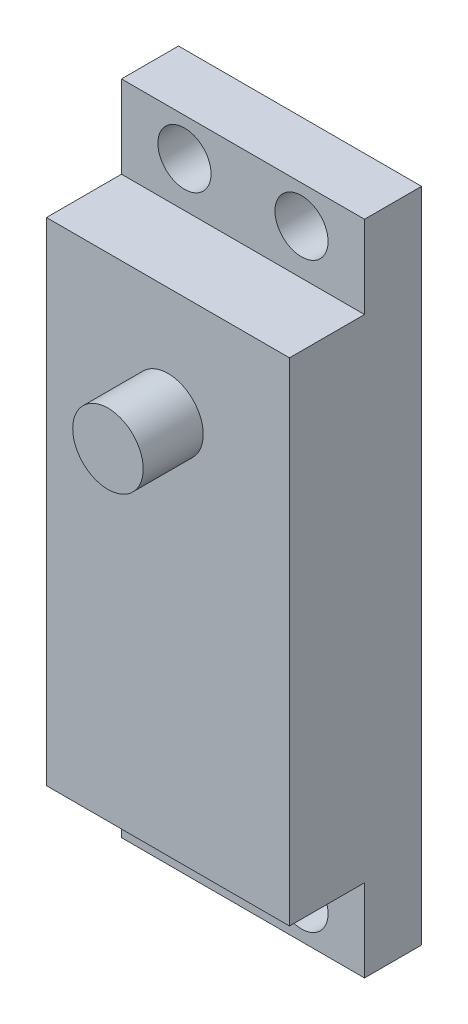
from build123d import *

# Parameters (mm, degrees)
SKETCH1_W             = 20.574
SKETCH1_H             = 55.626
BOSS_EXTRUDE1_DEPTH   = 11.176
SKETCH2_R             = 2.9845
BOSS_EXTRUDE2_DEPTH   = 5.08
F_8_CLEARANCE_HOLE1_D = 4.4958
MIRROR2_COPY_1_D      = 4.4958
SKETCH6_W             = 6.35
SKETCH6_H             = 6.985
CUT_EXTRUDE1_DEPTH    = 21.574


with BuildPart() as part:
    # Sketch1 → Boss-Extrude1 (new body)
    with BuildSketch(Plane.XY):
        Rectangle(SKETCH1_W, SKETCH1_H)
    extrude(amount=BOSS_EXTRUDE1_DEPTH)

    # Sketch2 → Boss-Extrude2 (add)
    with BuildSketch(Plane.XY.offset(11.176)):
        with Locations((0, 11.557)):
            Circle(SKETCH2_R)
    extrude(amount=BOSS_EXTRUDE2_DEPTH)

    # #8 Clearance Hole1 (through all)
    with Locations(Plane(origin=(0, 0, 0), x_dir=(-1, 0, 0), z_dir=(0, 0, -1))):
        with Locations((4.953, 24.638)):
            f_8_clearance_hole1 = Hole(F_8_CLEARANCE_HOLE1_D / 2)

    # Mirror1: #8 Clearance Hole1 across plane
    add(f_8_clearance_hole1.mirror(Plane(origin=(0, 0, 0), x_dir=(0, 0, 1), z_dir=(1, 0, 0))), mode=Mode.SUBTRACT)

    # Mirror2: #8 Clearance Hole1 across plane
    add(f_8_clearance_hole1.mirror(Plane.ZX), mode=Mode.SUBTRACT)

    # Mirror2 copy 1 (through all)
    with Locations(Plane(origin=(0, 0, 0), x_dir=(1, 0, 0), z_dir=(0, 0, -1))):
        with Locations((4.953, 24.638)):
            Hole(MIRROR2_COPY_1_D / 2)

    # Sketch6 → Cut-Extrude1 (cut, through all)
    with BuildSketch(Plane.ZY.offset(10.287)):
        with Locations((8.001, -24.3205)):
            Rectangle(SKETCH6_W, SKETCH6_H)
        with Locations((8.001, 24.3205)):
            Rectangle(SKETCH6_W, SKETCH6_H)
    extrude(amount=-CUT_EXTRUDE1_DEPTH, mode=Mode.SUBTRACT)


solid = part.part
